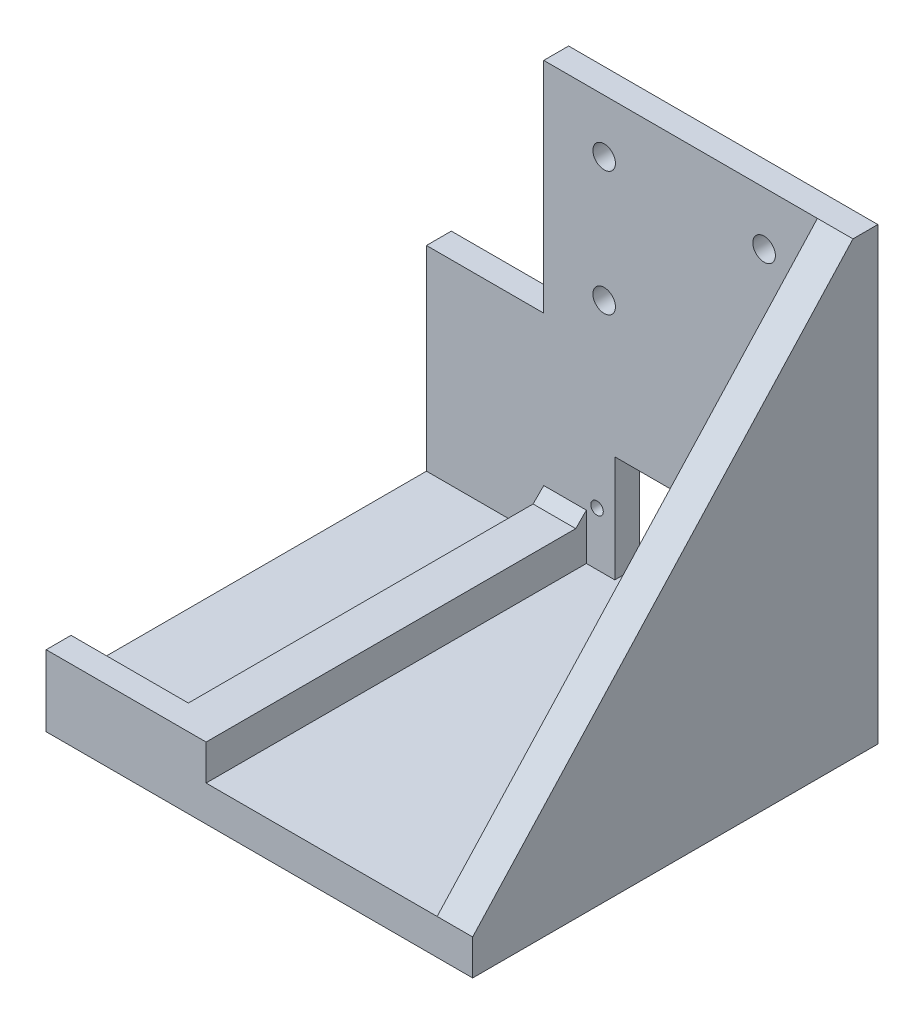
from build123d import *

# Parameters (mm, degrees)
SKETCH1_W           = 110
SKETCH1_H           = 114
BOSS_EXTRUDE1_DEPTH = 10
BOSS_EXTRUDE2_DEPTH = 10
SKETCH4_W           = 110
SKETCH4_H           = 7
BOSS_EXTRUDE3_DEPTH = 116.6
SKETCH12_W          = 33
SKETCH12_H          = 7
CUT_EXTRUDE6_DEPTH  = 61.6
SKETCH8_W           = 26
SKETCH8_H           = 30
CUT_EXTRUDE3_DEPTH  = 8
SKETCH9_W           = 13
SKETCH9_H           = 19.5
CUT_EXTRUDE4_DEPTH  = 8
SKETCH10_W          = 17
SKETCH10_H          = 23.5
CUT_EXTRUDE5_DEPTH  = 4
SKETCH6_R           = 3.175
CUT_EXTRUDE1_DEPTH  = 8
BOSS_EXTRUDE5_DEPTH = 10
SKETCH14_R          = 1.75
CUT_EXTRUDE7_DEPTH  = 115
CHAMFER2_SIZE       = 3


with BuildPart() as part:
    # Sketch1 → Boss-Extrude1 (new body)
    with BuildSketch(Plane(origin=(0, 0, 0), x_dir=(1, 0, 0), z_dir=(0, 1, 0))):
        Rectangle(SKETCH1_W, SKETCH1_H)
    extrude(amount=-BOSS_EXTRUDE1_DEPTH)

    # Sketch3 → Boss-Extrude2 (add)
    with BuildSketch(Plane(origin=(0, 0, 0), x_dir=(1, 0, 0), z_dir=(0, 1, 0))):
        Polygon((-55, -50), (-55, -57), (-10, -57), (-10, 57), (-55, 57), (-55, 50), (-22, 50), (-22, -50), align=None)
    extrude(amount=BOSS_EXTRUDE2_DEPTH)

    # Sketch4 → Boss-Extrude3 (add)
    with BuildSketch(Plane(origin=(0, 0, 0), x_dir=(1, 0, 0), z_dir=(0, 1, 0))):
        with Locations((0, 53.5)):
            Rectangle(SKETCH4_W, SKETCH4_H)
    extrude(amount=BOSS_EXTRUDE3_DEPTH)

    # Sketch12 → Cut-Extrude6 (cut)
    with BuildSketch(Plane(origin=(0, 116.6, 0), x_dir=(1, 0, 0), z_dir=(0, 1, 0))):
        with Locations((-38.5, 53.5)):
            Rectangle(SKETCH12_W, SKETCH12_H)
    extrude(amount=-CUT_EXTRUDE6_DEPTH, mode=Mode.SUBTRACT)

    # Sketch8 → Cut-Extrude3 (cut, through all)
    with BuildSketch(Plane.XY.offset(-50)):
        with Locations((11, 15)):
            Rectangle(SKETCH8_W, SKETCH8_H)
    extrude(amount=-CUT_EXTRUDE3_DEPTH, mode=Mode.SUBTRACT)

    # Sketch9 → Cut-Extrude4 (cut, through all)
    with BuildSketch(Plane.XY.offset(-50)):
        with Locations((43.5, 12.75)):
            Rectangle(SKETCH9_W, SKETCH9_H)
    extrude(amount=-CUT_EXTRUDE4_DEPTH, mode=Mode.SUBTRACT)

    # Sketch10 → Cut-Extrude5 (cut)
    with BuildSketch(Plane.XY.offset(-50)):
        with Locations((43.5, 12.75)):
            Rectangle(SKETCH10_W, SKETCH10_H)
    extrude(amount=-CUT_EXTRUDE5_DEPTH, mode=Mode.SUBTRACT)

    # Sketch6 → Cut-Extrude1 (cut, through all)
    with BuildSketch(Plane.XY.offset(-50)):
        with Locations((-5, 101.6)):
            Circle(SKETCH6_R)
        with Locations((40, 101.6)):
            Circle(SKETCH6_R)
        with Locations((-5, 66.6)):
            Circle(SKETCH6_R)
        with Locations((40, 66.6)):
            Circle(SKETCH6_R)
    extrude(amount=-CUT_EXTRUDE1_DEPTH, mode=Mode.SUBTRACT)

    # Sketch11 → Boss-Extrude5 (add)
    with BuildSketch(Plane(origin=(55, 0, 0), x_dir=(0, 0, -1), z_dir=(1, 0, 0))):
        Polygon((57, 116.6), (50, 116.6), (-57, 0), (-57, -10), (57, -10), align=None)
    extrude(amount=BOSS_EXTRUDE5_DEPTH)

    # Sketch14 → Cut-Extrude7 (cut, through all)
    with BuildSketch(Plane(origin=(0, 0, -57), x_dir=(-1, 0, 0), z_dir=(0, 0, -1))):
        with Locations((-29, 15)):
            Circle(SKETCH14_R)
        with Locations((7, 15)):
            Circle(SKETCH14_R)
    extrude(amount=-CUT_EXTRUDE7_DEPTH, mode=Mode.SUBTRACT)

    # Chamfer2
    chamfer2_edges = [part.edges().sort_by_distance(p)[0] for p in [
        (-16, 10, -50),
    ]]
    chamfer(chamfer2_edges, length=CHAMFER2_SIZE)


solid = part.part
